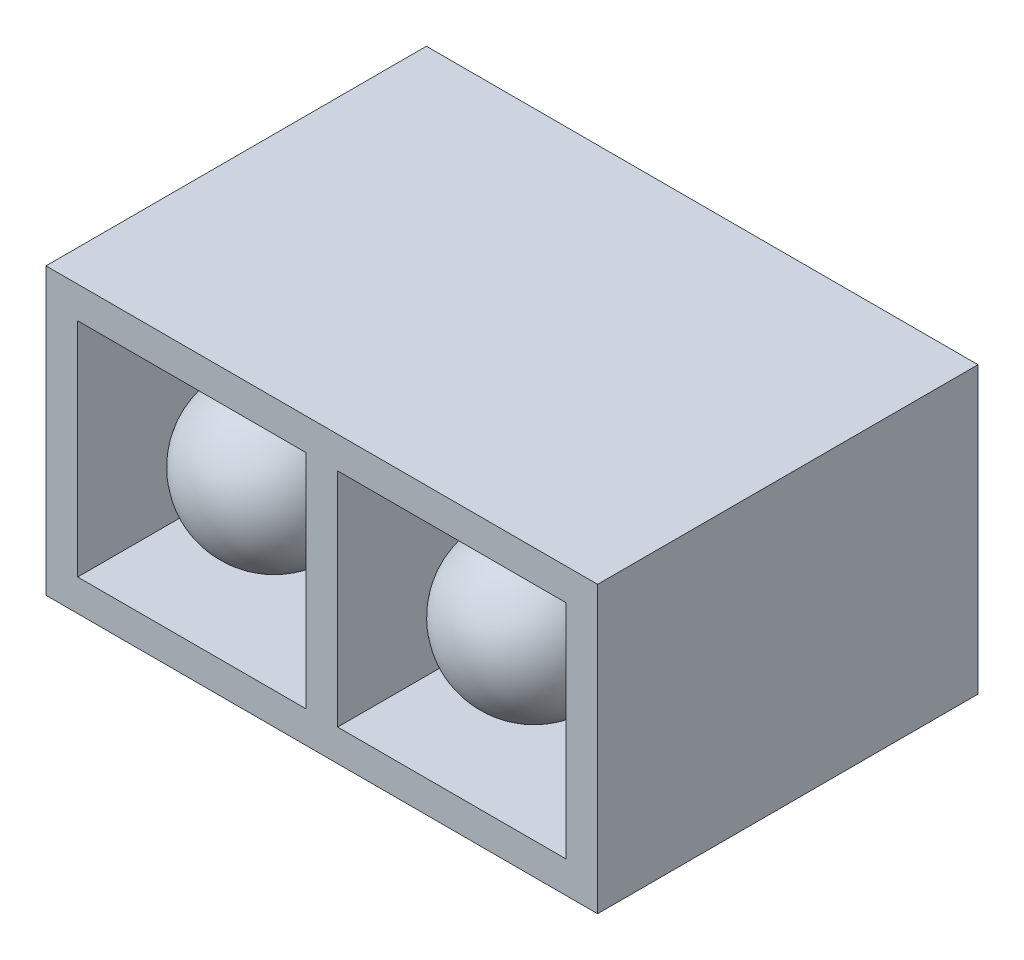
from build123d import *

# Parameters (mm, degrees)
ESQUISSE1_W        = 8.7
ESQUISSE1_H        = 4.5
ESQUISSE1_W_2      = 7.7
ESQUISSE1_H_2      = 3.5
EXTRU_MINCE1_DEPTH = 6
ESQUISSE2_W        = 0.5
ESQUISSE2_H        = 4.5
BOSS_EXTRU_1_DEPTH = 6
ESQUISSE3_W        = 8.7
ESQUISSE3_H        = 4.5
BOSS_EXTRU_2_DEPTH = 2


with BuildPart() as part:
    # Esquisse1 → Extru.-Mince1 (new body)
    with BuildSketch(Plane.XY):
        Rectangle(ESQUISSE1_W, ESQUISSE1_H)
        Rectangle(ESQUISSE1_W_2, ESQUISSE1_H_2, mode=Mode.SUBTRACT)
    extrude(amount=EXTRU_MINCE1_DEPTH)

    # Esquisse2 → Boss.-Extru.1 (add)
    with BuildSketch(Plane.XY):
        Rectangle(ESQUISSE2_W, ESQUISSE2_H)
    extrude(amount=BOSS_EXTRU_1_DEPTH)

    # Esquisse3 → Boss.-Extru.2 (add)
    with BuildSketch(Plane(origin=(0, 0, 0), x_dir=(-1, 0, 0), z_dir=(0, 0, -1))):
        Rectangle(ESQUISSE3_W, ESQUISSE3_H)
    extrude(amount=-BOSS_EXTRU_2_DEPTH)

    # Esquisse5 → Révolution1 (revolve)
    with BuildSketch(Plane(origin=(0, 0, 0), x_dir=(1, 0, 0), z_dir=(0, 1, 0))):
        with BuildLine():
            Line((-3.25, -4.7), (-3.25, -2))
            Line((-3.25, -2), (-2.05, -2))
            Line((-2.05, -2), (-2.05, -5.9))
            ThreePointArc((-2.05, -5.9), (-2.898528137, -5.548528137), (-3.25, -4.7))
        make_face()
    revolve(axis=Axis((-2.05, 0, 1.184517664), (0, 0, 1)))

    # Esquisse6 → Révolution2 (revolve)
    with BuildSketch(Plane(origin=(0, 0, 0), x_dir=(1, 0, 0), z_dir=(0, 1, 0))):
        with BuildLine():
            Line((0.85, -4.7), (0.85, -2))
            Line((0.85, -2), (2.05, -2))
            Line((2.05, -2), (2.05, -5.9))
            ThreePointArc((2.05, -5.9), (1.201471863, -5.548528137), (0.85, -4.7))
        make_face()
    revolve(axis=Axis((2.05, 0, 1.406149481), (0, 0, 1)))


solid = part.part
